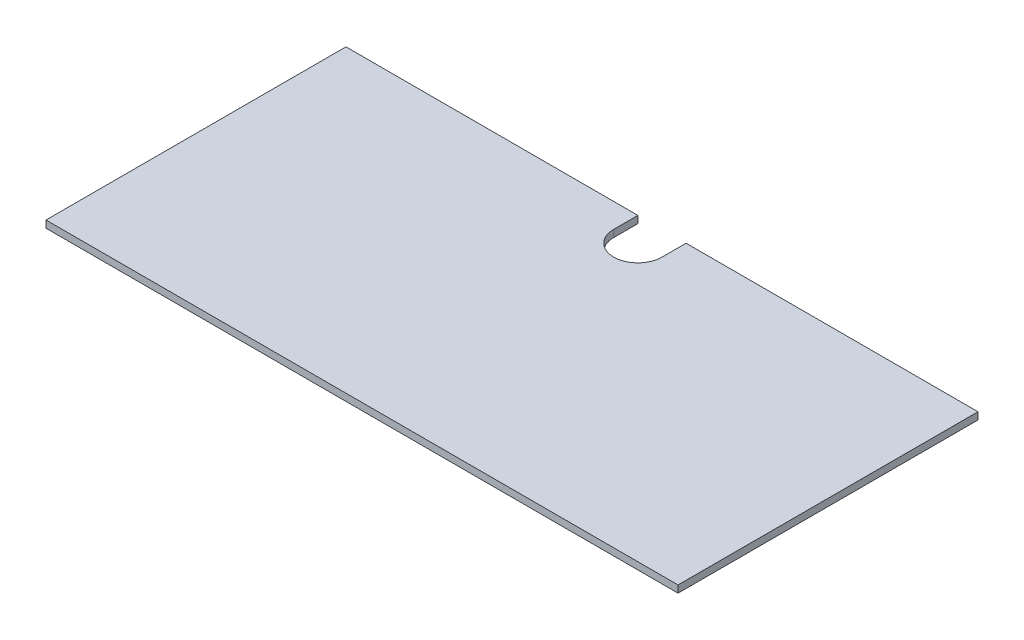
from build123d import *

# Parameters (mm, degrees)
BOSS_EXTRUDE1_DEPTH = 6.35


with BuildPart() as part:
    # Sketch2 → Boss-Extrude1 (new body)
    with BuildSketch(Plane(origin=(0, 0, 0), x_dir=(1, 0, 0), z_dir=(0, 1, 0))):
        with BuildLine():
            Line((302.41875, 266.7), (561.975, 266.7))
            Line((561.975, 266.7), (561.975, 0))
            Line((561.975, 0), (0, 0))
            Line((0, 0), (0, 266.7))
            Line((0, 266.7), (259.55625, 266.7))
            Line((259.55625, 266.7), (259.55625, 245.26875))
            ThreePointArc((259.55625, 245.26875), (280.9875, 223.8375), (302.41875, 245.26875))
            Line((302.41875, 245.26875), (302.41875, 266.7))
        make_face()
    extrude(amount=BOSS_EXTRUDE1_DEPTH)


solid = part.part
